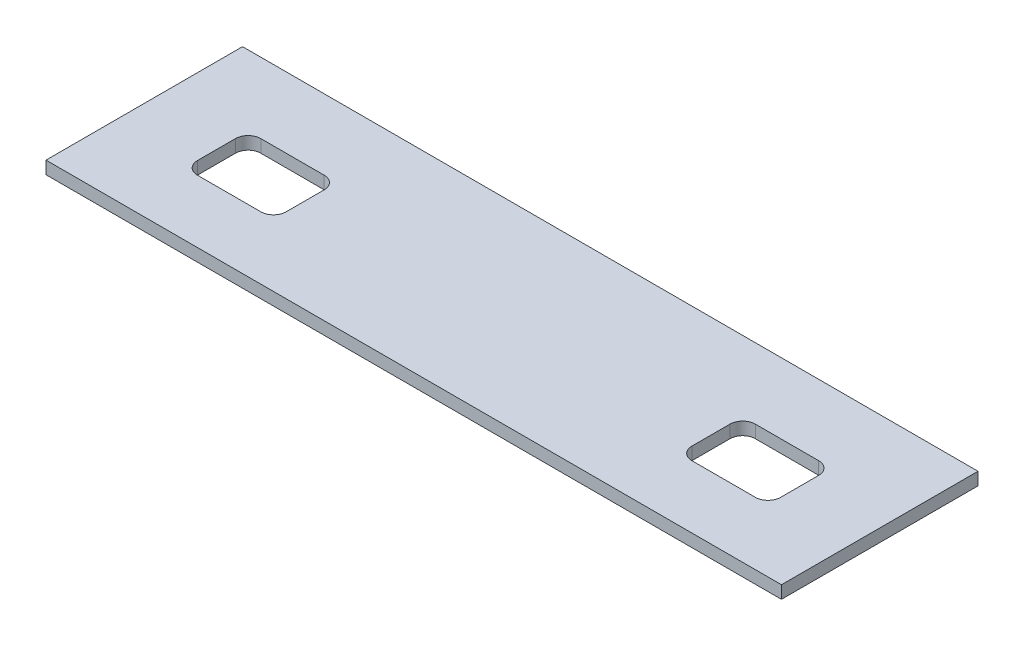
from build123d import *

# Parameters (mm, degrees)
ESQUISSE1_W             = 580
ESQUISSE1_H             = 155
BOSS_EXTRU_1_DEPTH      = 10
ENL_V_MAT_EXTRU_1_DEPTH = 10


with BuildPart() as part:
    # Esquisse1 → Boss.-Extru.1 (new body)
    with BuildSketch(Plane(origin=(0, 0, 0), x_dir=(1, 0, 0), z_dir=(0, 1, 0))):
        with Locations((290, 77.5)):
            Rectangle(ESQUISSE1_W, ESQUISSE1_H)
    extrude(amount=BOSS_EXTRU_1_DEPTH)

    # Esquisse2 → Enlèv. mat.-Extru.1 (cut)
    with BuildSketch(Plane(origin=(0, 10, 0), x_dir=(1, 0, 0), z_dir=(0, 1, 0))):
        with BuildLine():
            Line((70, 99.405892869), (120, 99.405892869))
            ThreePointArc((120, 99.405892869), (127.071067812, 96.476960681), (130, 89.405892869))
            Line((130, 89.405892869), (130, 59.405892869))
            ThreePointArc((130, 59.405892869), (127.071067812, 52.334825057), (120, 49.405892869))
            Line((120, 49.405892869), (70, 49.405892869))
            ThreePointArc((70, 49.405892869), (62.928932188, 52.334825057), (60, 59.405892869))
            Line((60, 59.405892869), (60, 89.405892869))
            ThreePointArc((60, 89.405892869), (62.928932188, 96.476960681), (70, 99.405892869))
        make_face()
        with BuildLine():
            Line((460, 99.405892869), (510, 99.405892869))
            ThreePointArc((510, 99.405892869), (517.071067812, 96.476960681), (520, 89.405892869))
            Line((520, 89.405892869), (520, 59.405892869))
            ThreePointArc((520, 59.405892869), (517.071067812, 52.334825057), (510, 49.405892869))
            Line((510, 49.405892869), (460, 49.405892869))
            ThreePointArc((460, 49.405892869), (452.928932188, 52.334825057), (450, 59.405892869))
            Line((450, 59.405892869), (450, 89.405892869))
            ThreePointArc((450, 89.405892869), (452.928932188, 96.476960681), (460, 99.405892869))
        make_face()
    extrude(amount=-ENL_V_MAT_EXTRU_1_DEPTH, mode=Mode.SUBTRACT)


solid = part.part
